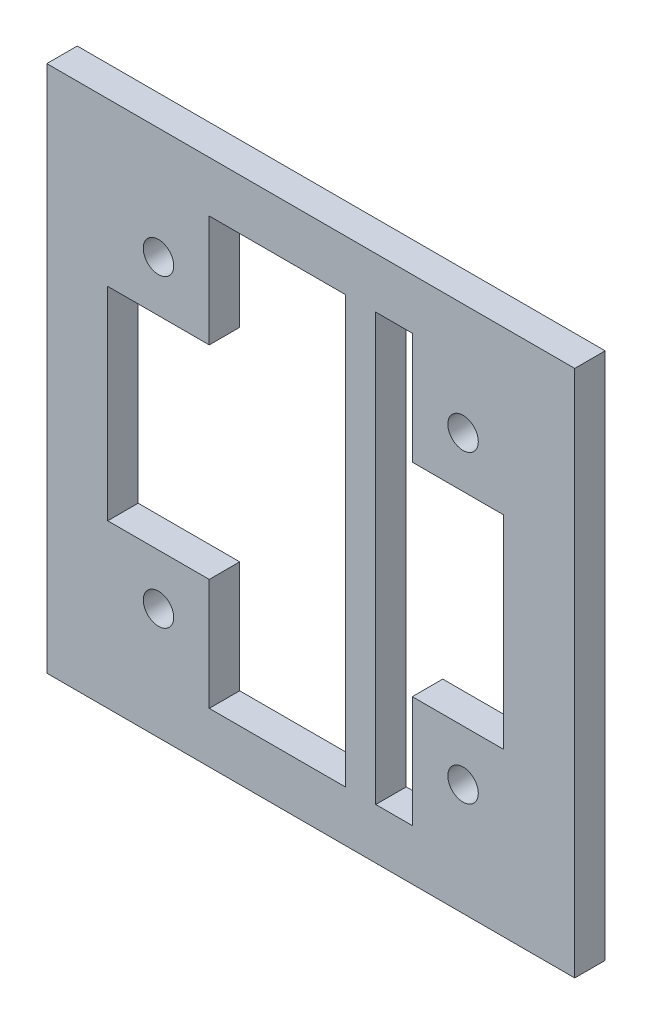
from build123d import *

# Parameters (mm, degrees)
MODEL_W                 = 52
MODEL_H                 = 52
MODEL_R                 = 1.5
SALIENTE_EXTRUIR1_DEPTH = 3


with BuildPart() as part:
    # Model → Saliente-Extruir1 (new body)
    with BuildSketch(Plane.XY):
        with Locations((66, 205)):
            Rectangle(MODEL_W, MODEL_H)
        with Locations((51, 190)):
            Circle(MODEL_R, mode=Mode.SUBTRACT)
        with Locations((81, 190)):
            Circle(MODEL_R, mode=Mode.SUBTRACT)
        with Locations((81, 220)):
            Circle(MODEL_R, mode=Mode.SUBTRACT)
        with Locations((51, 220)):
            Circle(MODEL_R, mode=Mode.SUBTRACT)
        Polygon((56, 226), (56, 215), (46, 215), (46, 195), (56, 195), (56, 184), (69.4, 184), (69.4, 226), align=None, mode=Mode.SUBTRACT)
        Polygon((72.4, 226), (72.4, 184), (76, 184), (76, 195), (85, 195), (85, 215), (76, 215), (76, 226), align=None, mode=Mode.SUBTRACT)
    extrude(amount=SALIENTE_EXTRUIR1_DEPTH)


solid = part.part
